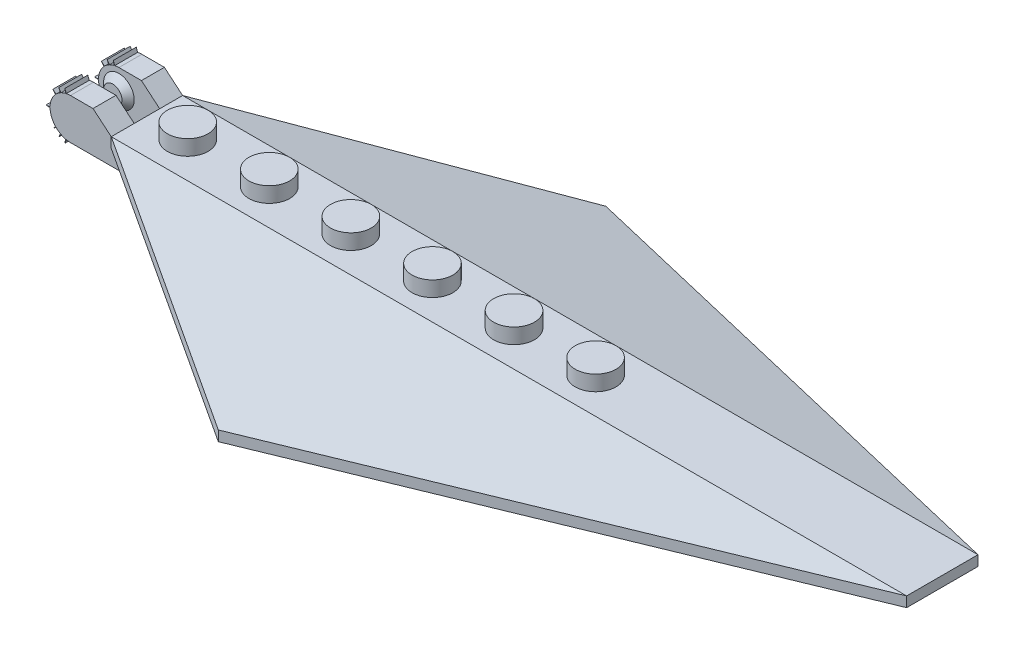
from build123d import *

# Parameters (mm, degrees)
SKETCH1_W                       = 60.96
SKETCH1_H                       = 3.175
BOSS_EXTRUDE1_DEPTH             = 4.445
SKETCH3_R                       = 2.54
BOSS_EXTRUDE2_DEPTH             = 1.905
SKETCH4_W                       = 38.1
SKETCH4_H                       = 8.89
BOSS_EXTRUDE3_DEPTH             = 1.27
BOSS_EXTRUDE4_DEPTH             = 68.58
BOSS_EXTRUDE4_DEPTH_BACK        = 30.48
CUT_EXTRUDE1_DEPTH              = 2.905
CUT_EXTRUDE1_DEPTH_BACK         = 7.544579853
BOSS_EXTRUDE5_REACH             = 26.13
BOSS_EXTRUDE5_DIRECTION_2_REACH = 26.13
SKETCH9_W                       = 11.711761908
SKETCH9_H                       = 3.175
CUT_EXTRUDE2_DEPTH              = 3.328072262
CUT_EXTRUDE2_DEPTH_BACK         = 7.544579853
SKETCH10_R                      = 1.905
BOSS_EXTRUDE6_DEPTH             = 0.762
BOSS_EXTRUDE6_TAPER             = 45
SKETCH11_W                      = 58.42
SKETCH11_H                      = 5.08
CUT_EXTRUDE3_DEPTH              = 1.905
SKETCH12_R                      = 1.905
CUT_EXTRUDE5_DEPTH              = 2.54
SKETCH13_R                      = 1.905
SKETCH13_R_2                    = 0.9525
BOSS_EXTRUDE7_DEPTH             = 1.905


with BuildPart() as part:
    # Sketch1 → Boss-Extrude1 (new body, symmetric)
    with BuildSketch(Plane.XY):
        with Locations((0, -1.5875)):
            Rectangle(SKETCH1_W, SKETCH1_H)
    extrude(amount=BOSS_EXTRUDE1_DEPTH, both=True)

    # Sketch3 → Boss-Extrude2 (add)
    with BuildSketch(Plane(origin=(0, 0, 0), x_dir=(1, 0, 0), z_dir=(0, 1, 0))):
        with Locations((-25.4, 0)):
            Circle(SKETCH3_R)
        with Locations((-15.24, 0)):
            Circle(SKETCH3_R)
        with Locations((-5.08, 0)):
            Circle(SKETCH3_R)
        with Locations((5.08, 0)):
            Circle(SKETCH3_R)
        with Locations((15.24, 0)):
            Circle(SKETCH3_R)
        with Locations((25.4, 0)):
            Circle(SKETCH3_R)
    extrude(amount=BOSS_EXTRUDE2_DEPTH)

    # Sketch4 → Boss-Extrude3 (add)
    with BuildSketch(Plane(origin=(0, 0, 0), x_dir=(1, 0, 0), z_dir=(0, 1, 0))):
        with Locations((49.53, 0)):
            Rectangle(SKETCH4_W, SKETCH4_H)
    extrude(amount=-BOSS_EXTRUDE3_DEPTH)

    # Sketch5 → Boss-Extrude4 (add, two sides)
    with BuildSketch(Plane(origin=(0, 0, 0), x_dir=(0, 0, -1), z_dir=(1, 0, 0))) as boss_extrude4_sk:
        Polygon((4.445, 0), (24.13, -5.274579853), (24.13, -6.544579853), (4.445, -1.27), align=None)
        Polygon((-24.13, -6.544579853), (-24.13, -5.274579853), (-4.445, 0), (-4.445, -1.27), align=None)
    extrude(amount=BOSS_EXTRUDE4_DEPTH)
    extrude(boss_extrude4_sk.sketch, amount=-BOSS_EXTRUDE4_DEPTH_BACK)

    # Sketch7 → Cut-Extrude1 (cut, two sides)
    with BuildSketch(Plane(origin=(0, 0, 0), x_dir=(1, 0, 0), z_dir=(0, 1, 0))) as cut_extrude1_sk:
        Polygon((-30.48, 24.13), (-30.48, 4.445), (2.54, 24.13), align=None)
        Polygon((68.58, 24.13), (2.54, 24.13), (68.58, 4.445), align=None)
        Polygon((2.54, -24.13), (68.58, -4.445), (68.58, -24.13), align=None)
        Polygon((-30.48, -4.445), (-30.48, -24.13), (2.54, -24.13), align=None)
    extrude(amount=CUT_EXTRUDE1_DEPTH, mode=Mode.SUBTRACT)
    extrude(cut_extrude1_sk.sketch, amount=-CUT_EXTRUDE1_DEPTH_BACK, mode=Mode.SUBTRACT)

    # Boss-Extrude5: up to this face of the body (flat: up to its plane)
    boss_extrude5_end = Plane(part.part.faces().sort_by_distance((0, -2.2225, 4.445))[0])
    # Sketch8 → Boss-Extrude5 (add, up to the picked face)
    with BuildSketch(Plane.XY, mode=Mode.PRIVATE) as boss_extrude5_sk1:
        with BuildLine():
            Line((-30.48, -3.175), (-35.56, -3.175))
            ThreePointArc((-35.56, -3.175), (-35.822583927, -3.161390643), (-36.082353996, -3.120708411))
            Line((-36.082353996, -3.120708411), (-36.256100229, -3.598072262))
            Line((-36.256100229, -3.598072262), (-36.168460823, -3.10104449))
            ThreePointArc((-36.168460823, -3.10104449), (-36.455050568, -3.012074774), (-36.729147494, -2.889926637))
            Line((-36.729147494, -2.889926637), (-37.020524323, -3.306055875))
            Line((-37.020524323, -3.306055875), (-36.806879146, -2.847892314))
            ThreePointArc((-36.806879146, -2.847892314), (-37.096571594, -2.657510256), (-37.357643969, -2.429457066))
            Line((-37.357643969, -2.429457066), (-37.746641055, -2.755864377))
            Line((-37.746641055, -2.755864377), (-37.419184284, -2.365616595))
            ThreePointArc((-37.419184284, -2.365616595), (-37.915481622, -1.585424288), (-38.099614088, -0.679275117))
            Line((-38.099614088, -0.679275117), (-38.605680994, -0.635))
            Line((-38.605680994, -0.635), (-38.099614088, -0.590724883))
            ThreePointArc((-38.099614088, -0.590724883), (-37.915481622, 0.315424288), (-37.419184284, 1.095616595))
            Line((-37.419184284, 1.095616595), (-37.746641055, 1.485864377))
            Line((-37.746641055, 1.485864377), (-37.357643969, 1.159457066))
            ThreePointArc((-37.357643969, 1.159457066), (-37.096571594, 1.387510256), (-36.806879146, 1.577892314))
            Line((-36.806879146, 1.577892314), (-37.020524323, 2.036055875))
            Line((-37.020524323, 2.036055875), (-36.729147494, 1.619926637))
            ThreePointArc((-36.729147494, 1.619926637), (-36.455050568, 1.742074774), (-36.168460823, 1.83104449))
            Line((-36.168460823, 1.83104449), (-36.256100229, 2.328072262))
            Line((-36.256100229, 2.328072262), (-36.082353996, 1.850708411))
            ThreePointArc((-36.082353996, 1.850708411), (-35.822583927, 1.891390643), (-35.56, 1.905))
            Line((-35.56, 1.905), (-32.750290594, 1.905))
            Line((-32.750290594, 1.905), (-30.48, 0))
            Line((-30.48, 0), (-30.48, -3.175))
        make_face()
    boss_extrude5_tool1 = split(extrude(boss_extrude5_sk1.sketch, amount=BOSS_EXTRUDE5_REACH, mode=Mode.PRIVATE), bisect_by=boss_extrude5_end, keep=Keep.BOTH, mode=Mode.PRIVATE)
    add(boss_extrude5_tool1.solids().sort_by_distance((-34.232672, -0.756395, 0))[0])

    # Boss-Extrude5 direction 2: up to this face of the body (flat: up to its plane)
    boss_extrude5_direction_2_end = Plane(part.part.faces().sort_by_distance((0, -2.2225, -4.445))[0])
    # Sketch8 → Boss-Extrude5 direction 2 (add, up to the picked face)
    with BuildSketch(Plane.XY, mode=Mode.PRIVATE) as boss_extrude5_direction_2_sk1:
        with BuildLine():
            Line((-30.48, -3.175), (-35.56, -3.175))
            ThreePointArc((-35.56, -3.175), (-35.822583927, -3.161390643), (-36.082353996, -3.120708411))
            Line((-36.082353996, -3.120708411), (-36.256100229, -3.598072262))
            Line((-36.256100229, -3.598072262), (-36.168460823, -3.10104449))
            ThreePointArc((-36.168460823, -3.10104449), (-36.455050568, -3.012074774), (-36.729147494, -2.889926637))
            Line((-36.729147494, -2.889926637), (-37.020524323, -3.306055875))
            Line((-37.020524323, -3.306055875), (-36.806879146, -2.847892314))
            ThreePointArc((-36.806879146, -2.847892314), (-37.096571594, -2.657510256), (-37.357643969, -2.429457066))
            Line((-37.357643969, -2.429457066), (-37.746641055, -2.755864377))
            Line((-37.746641055, -2.755864377), (-37.419184284, -2.365616595))
            ThreePointArc((-37.419184284, -2.365616595), (-37.915481622, -1.585424288), (-38.099614088, -0.679275117))
            Line((-38.099614088, -0.679275117), (-38.605680994, -0.635))
            Line((-38.605680994, -0.635), (-38.099614088, -0.590724883))
            ThreePointArc((-38.099614088, -0.590724883), (-37.915481622, 0.315424288), (-37.419184284, 1.095616595))
            Line((-37.419184284, 1.095616595), (-37.746641055, 1.485864377))
            Line((-37.746641055, 1.485864377), (-37.357643969, 1.159457066))
            ThreePointArc((-37.357643969, 1.159457066), (-37.096571594, 1.387510256), (-36.806879146, 1.577892314))
            Line((-36.806879146, 1.577892314), (-37.020524323, 2.036055875))
            Line((-37.020524323, 2.036055875), (-36.729147494, 1.619926637))
            ThreePointArc((-36.729147494, 1.619926637), (-36.455050568, 1.742074774), (-36.168460823, 1.83104449))
            Line((-36.168460823, 1.83104449), (-36.256100229, 2.328072262))
            Line((-36.256100229, 2.328072262), (-36.082353996, 1.850708411))
            ThreePointArc((-36.082353996, 1.850708411), (-35.822583927, 1.891390643), (-35.56, 1.905))
            Line((-35.56, 1.905), (-32.750290594, 1.905))
            Line((-32.750290594, 1.905), (-30.48, 0))
            Line((-30.48, 0), (-30.48, -3.175))
        make_face()
    boss_extrude5_direction_2_tool1 = split(extrude(boss_extrude5_direction_2_sk1.sketch, amount=-BOSS_EXTRUDE5_DIRECTION_2_REACH, mode=Mode.PRIVATE), bisect_by=boss_extrude5_direction_2_end, keep=Keep.BOTH, mode=Mode.PRIVATE)
    add(boss_extrude5_direction_2_tool1.solids().sort_by_distance((-34.232672, -0.756395, 0))[0])

    # Sketch9 → Cut-Extrude2 (cut, two sides)
    with BuildSketch(Plane(origin=(0, 0, 0), x_dir=(1, 0, 0), z_dir=(0, 1, 0))) as cut_extrude2_sk:
        with Locations((-36.335880954, 0)):
            Rectangle(SKETCH9_W, SKETCH9_H)
    extrude(amount=CUT_EXTRUDE2_DEPTH, mode=Mode.SUBTRACT)
    extrude(cut_extrude2_sk.sketch, amount=-CUT_EXTRUDE2_DEPTH_BACK, mode=Mode.SUBTRACT)

    # Sketch10 → Boss-Extrude6 (add)
    with BuildSketch(Plane.XY.offset(-1.5875)):
        with Locations((-35.56, -0.635)):
            Circle(SKETCH10_R)
    boss_extrude6 = extrude(amount=BOSS_EXTRUDE6_DEPTH, taper=BOSS_EXTRUDE6_TAPER)

    # Mirror1: Boss-Extrude6 across plane
    add(boss_extrude6.mirror(Plane.XY))

    # Sketch11 → Cut-Extrude3 (cut)
    with BuildSketch(Plane.XZ.offset(3.175)):
        Rectangle(SKETCH11_W, SKETCH11_H)
    extrude(amount=-CUT_EXTRUDE3_DEPTH, mode=Mode.SUBTRACT)

    # Sketch12 → Cut-Extrude5 (cut)
    with BuildSketch(Plane.XZ.offset(1.27)):
        with Locations((-25.4, 0)):
            Circle(SKETCH12_R)
        with Locations((-15.24, 0)):
            Circle(SKETCH12_R)
        with Locations((-5.08, 0)):
            Circle(SKETCH12_R)
        with Locations((5.08, 0)):
            Circle(SKETCH12_R)
        with Locations((15.24, 0)):
            Circle(SKETCH12_R)
        with Locations((25.4, 0)):
            Circle(SKETCH12_R)
    extrude(amount=-CUT_EXTRUDE5_DEPTH, mode=Mode.SUBTRACT)

    # Sketch13 → Boss-Extrude7 (add)
    with BuildSketch(Plane.XZ.offset(1.27)):
        with Locations((-20.32, 0)):
            Circle(SKETCH13_R)
        with Locations((-20.32, 0)):
            Circle(SKETCH13_R_2, mode=Mode.SUBTRACT)
        with Locations((-10.16, 0)):
            Circle(SKETCH13_R)
        with Locations((-10.16, 0)):
            Circle(SKETCH13_R_2, mode=Mode.SUBTRACT)
        with Locations((10.16, 0)):
            Circle(SKETCH13_R)
        with Locations((10.16, 0)):
            Circle(SKETCH13_R_2, mode=Mode.SUBTRACT)
        with Locations((20.32, 0)):
            Circle(SKETCH13_R)
        with Locations((20.32, 0)):
            Circle(SKETCH13_R_2, mode=Mode.SUBTRACT)
        Circle(SKETCH13_R)
        Circle(SKETCH13_R_2, mode=Mode.SUBTRACT)
    extrude(amount=BOSS_EXTRUDE7_DEPTH)


solid = part.part
